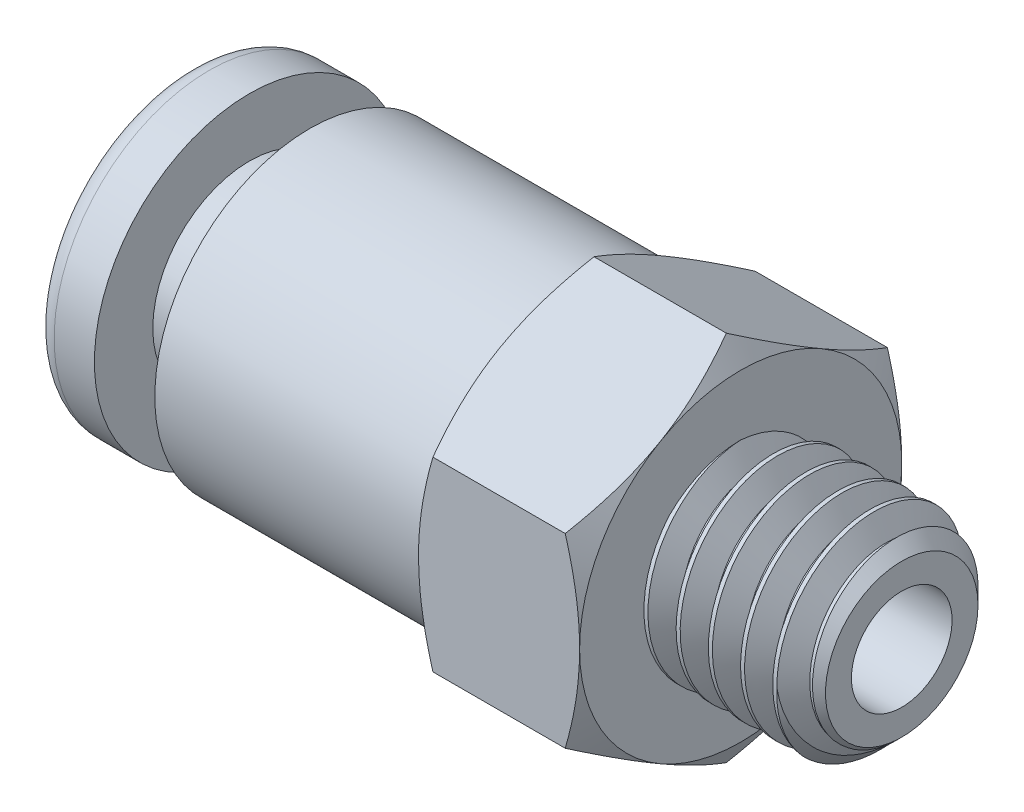
from build123d import *

# Parameters (mm, degrees)
SKETCH2_R          = 2.5
EXTRUDE1_DEPTH     = 4
SKETCH5_OUTSIDE_W  = 19.856
SKETCH5_OUTSIDE_H  = 19.856
SKETCH5_OUTSIDE_R  = 1.893782217
EXTRUDE2_DEPTH     = 3
EXTRUDE2_DRAFT     = -45
CUT_SWEEP1_PITCH   = 0.8
CUT_SWEEP1_HEIGHT  = 6.8
CUT_SWEEP1_RADIUS  = 2.5
SKETCH7_R          = 1.25
EXTRUDE4_DEPTH     = 17.7
SKETCH8_R          = 3.85
EXTRUDE5_DEPTH     = 4
SKETCH9_OUTSIDE_W  = 28.158
SKETCH9_OUTSIDE_H  = 29.396
SKETCH9_OUTSIDE_R  = 4
EXTRUDE6_DEPTH     = 4
EXTRUDE6_DRAFT     = -60
SKETCH10_OUTSIDE_W = 28.158
SKETCH10_OUTSIDE_H = 29.396
SKETCH10_OUTSIDE_R = 4
EXTRUDE7_DEPTH     = 4
EXTRUDE7_DRAFT     = -60


with BuildPart() as part:
    # Sketch1 → Revolve2 (revolve)
    with BuildSketch(Plane(origin=(0, 0, 0), x_dir=(-1, 0, 0), z_dir=(0, 0, -1)), mode=Mode.PRIVATE) as revolve2_sk:
        with BuildLine():
            Line((0, 3.35), (0, 2.5))
            Line((0, 2.5), (-0.5, 2))
            Line((-0.5, 2), (-13.3, 2))
            Line((-13.3, 2), (-13.3, 0))
            Line((-13.3, 0), (-13.7, 0))
            Line((-13.7, 0), (-13.7, 3.85))
            Line((-13.7, 3.85), (-3, 3.85))
            Line((-3, 3.85), (-3, 2.4))
            Line((-3, 2.4), (-1.5, 2.4))
            Line((-1.5, 2.4), (-1.5, 3.85))
            Line((-1.5, 3.85), (-0.5, 3.85))
            ThreePointArc((-0.5, 3.85), (-0.146446609, 3.703553391), (0, 3.35))
        make_face()
    revolve(revolve2_sk.sketch.rotate(Axis((0, 0, 0), (1, 0, 0)), 180), axis=Axis((0, 0, 0), (1, 0, 0)))


with BuildPart() as body_2:
    # Sketch2 → Extrude1 (new body)
    with BuildSketch(Plane(origin=(13.7, 0, 0), x_dir=(0, 0, -1), z_dir=(1, 0, 0))):
        Circle(SKETCH2_R)
    extrude(amount=EXTRUDE1_DEPTH)


with BuildPart() as extrude2_tool:
    # Sketch5 outside → Extrude2 (with draft: the straight prism first)
    with BuildSketch(Plane(origin=(17.7, 0, 0), x_dir=(0, 0, -1), z_dir=(1, 0, 0))):
        Rectangle(SKETCH5_OUTSIDE_W, SKETCH5_OUTSIDE_H)
        Circle(SKETCH5_OUTSIDE_R, mode=Mode.SUBTRACT)
    extrude(amount=-EXTRUDE2_DEPTH)
    # Extrude2: the draft: its side faces are tilted about the plane it starts from
    extrude2_sides = [extrude2_tool.faces().sort_by_distance(p)[0] for p in [
        (16.2, -9.928, 0),
        (16.2, 0, -9.928),
        (16.2, 9.928, 0),
        (16.2, 0, 9.928),
        (16.2, 0, 1.893782217),
    ]]
    draft(extrude2_sides, Plane(origin=(17.7, 0, 0), x_dir=(0, 0, -1), z_dir=(1, 0, 0)), EXTRUDE2_DRAFT)


with BuildPart() as body_2_1:
    add(body_2.part)

    # Extrude2: cut by extrude2_tool
    add(extrude2_tool.part, mode=Mode.SUBTRACT)

    # Cut-Sweep1: sweep along a helix
    with BuildLine() as cut_sweep1_path:
        Helix(CUT_SWEEP1_PITCH, CUT_SWEEP1_HEIGHT, CUT_SWEEP1_RADIUS, center=(17.7, 0, 0), direction=(-1, 0, 0))
    # Sketch4 → Cut-Sweep1 (sweep, cut)
    with BuildSketch(Plane(origin=(0, 0, 0), x_dir=(-1, 0, 0), z_dir=(0, 0, -1))):
        Polygon((-18.1, 1.980384758), (-18, 1.980384758), (-17.65, 2.58660254), (-18.4, 2.5), align=None)
    sweep(path=cut_sweep1_path.line, is_frenet=True, mode=Mode.SUBTRACT)


with BuildPart() as extrude4_tool:
    # Sketch7 → Extrude4 (new body)
    with BuildSketch(Plane(origin=(17.7, 0, 0), x_dir=(0, 0, -1), z_dir=(1, 0, 0))):
        with Locations(Location((0, 0, 0), (0, 0, 90))):
            Circle(SKETCH7_R)
    extrude(amount=-EXTRUDE4_DEPTH)


with BuildPart() as part_1:
    add(part.part)

    # Extrude4: cut by extrude4_tool
    add(extrude4_tool.part, mode=Mode.SUBTRACT)

    # Sketch8 → Extrude5 (add)
    with BuildSketch(Plane(origin=(13.7, 0, 0), x_dir=(0, 0, -1), z_dir=(1, 0, 0))):
        Polygon((0, 4.618802154), (-4, 2.309401077), (-4, -2.309401077), (0, -4.618802154), (4, -2.309401077), (4, 2.309401077), align=None)
        with Locations(Location((0, 0, 0), (0, 0, 270))):
            Circle(SKETCH8_R, mode=Mode.SUBTRACT)
    extrude(amount=-EXTRUDE5_DEPTH)


with BuildPart() as body_2_2:
    add(body_2_1.part)

    # Extrude4: cut by extrude4_tool
    add(extrude4_tool.part, mode=Mode.SUBTRACT)


with BuildPart() as extrude6_tool:
    # Sketch9 outside → Extrude6 (with draft: the straight prism first)
    with BuildSketch(Plane(origin=(13.7, 0, 0), x_dir=(0, 0, -1), z_dir=(1, 0, 0))):
        Rectangle(SKETCH9_OUTSIDE_W, SKETCH9_OUTSIDE_H)
        Circle(SKETCH9_OUTSIDE_R, mode=Mode.SUBTRACT)
    extrude(amount=-EXTRUDE6_DEPTH)
    # Extrude6: the draft: its side faces are tilted about the plane it starts from
    extrude6_sides = [extrude6_tool.faces().sort_by_distance(p)[0] for p in [
        (11.7, -14.698, 0),
        (11.7, 0, -14.079),
        (11.7, 14.698, 0),
        (11.7, 0, 14.079),
        (11.7, 0, 4),
    ]]
    draft(extrude6_sides, Plane(origin=(13.7, 0, 0), x_dir=(0, 0, -1), z_dir=(1, 0, 0)), EXTRUDE6_DRAFT)


with BuildPart() as part_2:
    add(part_1.part)

    # Extrude6: cut by extrude6_tool
    add(extrude6_tool.part, mode=Mode.SUBTRACT)


with BuildPart() as extrude7_tool:
    # Sketch10 outside → Extrude7 (with draft: the straight prism first)
    with BuildSketch(Plane.ZY.offset(-9.7)):
        Rectangle(SKETCH10_OUTSIDE_W, SKETCH10_OUTSIDE_H)
        Circle(SKETCH10_OUTSIDE_R, mode=Mode.SUBTRACT)
    extrude(amount=-EXTRUDE7_DEPTH)
    # Extrude7: the draft: its side faces are tilted about the plane it starts from
    extrude7_sides = [extrude7_tool.faces().sort_by_distance(p)[0] for p in [
        (11.7, -14.698, 0),
        (11.7, 0, 14.079),
        (11.7, 14.698, 0),
        (11.7, 0, -14.079),
        (11.7, 0, -4),
    ]]
    draft(extrude7_sides, Plane.ZY.offset(-9.7), EXTRUDE7_DRAFT)


with BuildPart() as part_3:
    add(part_2.part)

    # Extrude7: cut by extrude7_tool
    add(extrude7_tool.part, mode=Mode.SUBTRACT)


with BuildPart() as body_2_3:
    add(body_2_2.part)

    # Combine1: union part
    add(part_3.part)


solid = body_2_3.part
